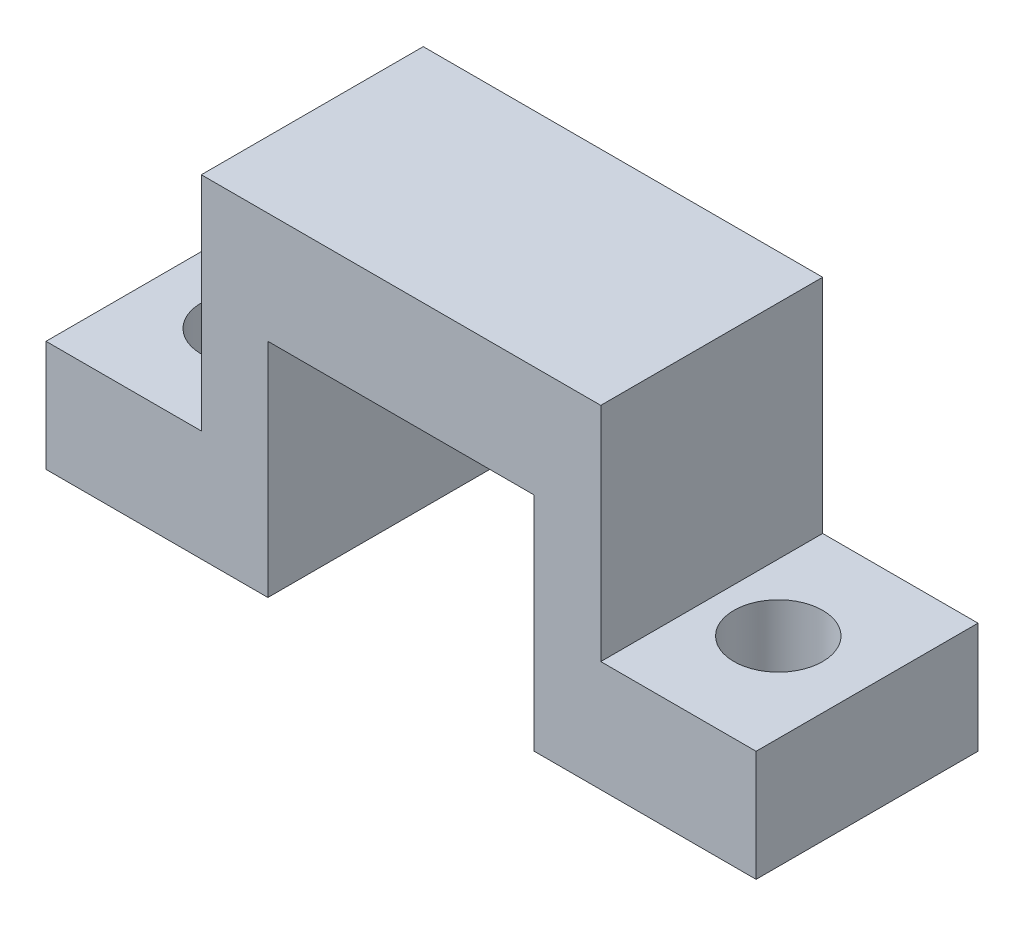
from build123d import *

# Parameters (mm, degrees)
RESSALTO_EXTRUS_O1_DEPTH = 10
ESBO_O2_R                = 2
CORTE_EXTRUS_O1_DEPTH    = 20
ESBO_O4_W                = 7
ESBO_O4_H                = 10
CORTE_EXTRUS_O2_DEPTH    = 20


with BuildPart() as part:
    # Esboço1 → Ressalto-extrusão1 (new body)
    with BuildSketch(Plane.XY):
        Polygon((32, 0), (32, 15), (0, 15), (0, 0), (10, 0), (10, 10), (22, 10), (22, 0), align=None)
    extrude(amount=RESSALTO_EXTRUS_O1_DEPTH)

    # Esboço2 → Corte-extrusão1 (cut)
    with BuildSketch(Plane(origin=(0, 0, 0), x_dir=(-1, 0, 0), z_dir=(0, -1, 0))):
        with Locations((-4, -5)):
            Circle(ESBO_O2_R)
        with Locations((-28, -5)):
            Circle(ESBO_O2_R)
    extrude(amount=-CORTE_EXTRUS_O1_DEPTH, mode=Mode.SUBTRACT)

    # Esboço4 → Corte-extrusão2 (cut)
    with BuildSketch(Plane(origin=(0, 0, 0), x_dir=(-1, 0, 0), z_dir=(0, 0, -1))):
        with Locations((-28.5, 10)):
            Rectangle(ESBO_O4_W, ESBO_O4_H)
        with Locations((-3.5, 10)):
            Rectangle(ESBO_O4_W, ESBO_O4_H)
    extrude(amount=-CORTE_EXTRUS_O2_DEPTH, mode=Mode.SUBTRACT)


solid = part.part
